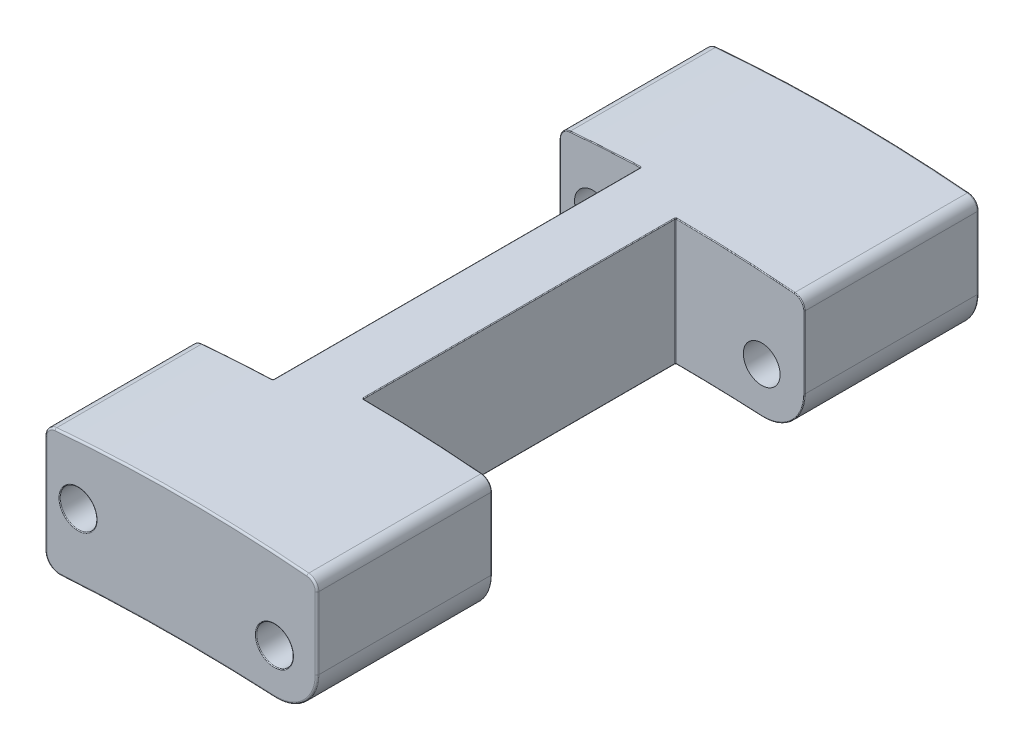
from build123d import *

# Parameters (mm, degrees)
SKETCH1_W           = 7.4
SKETCH1_H           = 3.7
BOSS_EXTRUDE1_DEPTH = 9
CUT_EXTRUDE1_DEPTH  = 24.8
FILLET1_R           = 1.1
FILLET2_R           = 0.3
SKETCH3_R           = 0.5
CUT_EXTRUDE2_DEPTH  = 24.8
FILLET4_R           = 0.02
FILLET5_R           = 0.4
FILLET6_R           = 0.05
SKETCH4_W           = 3.316991647
SKETCH4_H           = 10
SKETCH4_W_2         = 7.65842035
SKETCH4_H_2         = 8.5
CUT_EXTRUDE3_DEPTH  = 5
FILLET7_R           = 0.02


with BuildPart() as part:
    # Sketch1 → Boss-Extrude1 (new body, symmetric)
    with BuildSketch(Plane.XY):
        Rectangle(SKETCH1_W, SKETCH1_H)
    extrude(amount=BOSS_EXTRUDE1_DEPTH, both=True)

    # Sketch2 → Cut-Extrude1 (cut)
    with BuildSketch(Plane.XY.offset(9)):
        with BuildLine():
            Line((-3.7, 1.55), (-7.120690005, 4.011417256))
            Line((-7.120690005, 4.011417256), (5.535860742, 3.886722174))
            Line((5.535860742, 3.886722174), (3.7, 1.55))
            ThreePointArc((3.7, 1.55), (0, 1.721492621), (-3.7, 1.55))
        make_face()
        with BuildLine():
            Line((3.7, -1.85), (0.350623614, -3.782025322))
            Line((0.350623614, -3.782025322), (-3.7, -1.85))
            ThreePointArc((-3.7, -1.85), (0, -1.712912069), (3.7, -1.85))
        make_face()
    extrude(amount=-CUT_EXTRUDE1_DEPTH, mode=Mode.SUBTRACT)

    # Fillet1
    fillet1_edges = [part.edges().sort_by_distance(p)[0] for p in [
        (3.7, -1.85, 0),
    ]]
    fillet(fillet1_edges, radius=FILLET1_R)

    # Fillet2
    fillet2_edges = [part.edges().sort_by_distance(p)[0] for p in [
        (3.7, 1.55, 0),
        (-3.7, 1.55, 0),
    ]]
    fillet(fillet2_edges, radius=FILLET2_R)

    # Sketch3 → Cut-Extrude2 (cut)
    with BuildSketch(Plane.XY.offset(9)):
        with Locations((2.539436079, -0.548443568)):
            Circle(SKETCH3_R)
        with Locations((-2.8, 0)):
            Circle(SKETCH3_R)
    extrude(amount=-CUT_EXTRUDE2_DEPTH, mode=Mode.SUBTRACT)

    # Fillet4
    fillet4_edges = [part.edges().sort_by_distance(p)[0] for p in [
        (2.039436079, -0.548443568, -9),
        (2.039436079, -0.548443568, 9),
        (-3.3, 0, -9),
        (-3.3, 0, 9),
    ]]
    fillet(fillet4_edges, radius=FILLET4_R)

    # Fillet5
    fillet5_edges = [part.edges().sort_by_distance(p)[0] for p in [
        (-3.7, -1.85, 0),
    ]]
    fillet(fillet5_edges, radius=FILLET5_R)

    # Fillet6
    fillet6_edges = [part.edges().sort_by_distance(p)[0] for p in [
        (3.7, 0.298266493, -9),
        (3.7, 0.298266493, 9),
        (-0.365508237, -1.71424805, -9),
        (3.35777122, -1.476459629, -9),
        (-0.365508237, -1.71424805, 9),
        (3.35777122, -1.476459629, 9),
        (0, 1.721492621, 9),
        (-3.7, -0.072715545, 9),
        (-3.621029193, 1.478477738, 9),
        (3.621029193, 1.478477738, 9),
        (0, 1.721492621, -9),
        (-3.7, -0.072715545, -9),
        (-3.621029193, 1.478477738, -9),
        (3.621029193, 1.478477738, -9),
        (-3.573426233, -1.713019462, -9),
        (-3.573426233, -1.713019462, 9),
    ]]
    fillet(fillet6_edges, radius=FILLET6_R)

    # Sketch4 → Cut-Extrude3 (cut, symmetric)
    with BuildSketch(Plane(origin=(0, 0, 0), x_dir=(1, 0, 0), z_dir=(0, 1, 0))):
        with Locations((-3.158495824, 0)):
            Rectangle(SKETCH4_W, SKETCH4_H)
        with Locations((4.029210175, 0)):
            Rectangle(SKETCH4_W_2, SKETCH4_H_2)
    extrude(amount=CUT_EXTRUDE3_DEPTH, both=True, mode=Mode.SUBTRACT)

    # Fillet7
    fillet7_edges = [part.edges().sort_by_distance(p)[0] for p in [
        (-3.573426233, -1.713019462, 5),
        (-3.573426233, -1.713019462, -5),
        (-1.5, -1.735417134, 0),
        (-1.5, -0.021029703, -5),
        (-1.5, 1.693357727, 0),
        (-2.463562889, 1.645556266, -5),
        (-2.387281217, -1.769935702, -5),
        (-3.7, -0.072715545, -5),
        (-1.5, -0.021029703, 5),
        (-2.463562889, 1.645556266, 5),
        (-3.7, -0.072715545, 5),
        (-2.387281217, -1.769935702, 5),
        (-3.621029193, 1.478477738, -5),
        (-3.621029193, 1.478477738, 5),
        (0.2, -1.713312071, 0),
        (0.2, 0.003840274, 4.25),
        (0.2, 1.720992618, 0),
        (1.372393021, -1.731750244, -4.25),
        (0.2, 0.003840274, -4.25),
        (1.814324851, 1.680324253, -4.25),
        (3.7, 0.298266493, -4.25),
        (3.35777122, -1.476459629, -4.25),
        (3.621029193, 1.478477738, -4.25),
        (1.372393021, -1.731750244, 4.25),
        (3.7, 0.298266493, 4.25),
        (1.814324851, 1.680324253, 4.25),
        (3.621029193, 1.478477738, 4.25),
        (3.35777122, -1.476459629, 4.25),
    ]]
    fillet(fillet7_edges, radius=FILLET7_R)


solid = part.part
